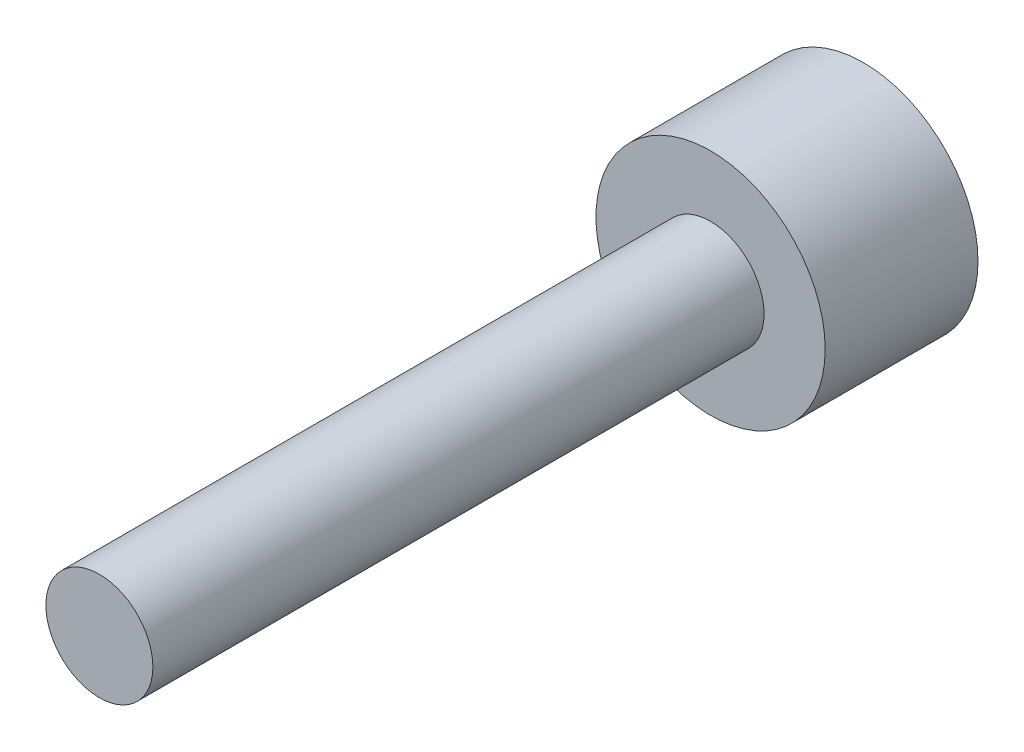
from build123d import *

# Parameters (mm, degrees)
SKETCH_1_R      = 0.7
EXTRUDE_1_DEPTH = 10
SKETCH_2_R      = 1.5
EXTRUDE_2_DEPTH = 2


with BuildPart() as part:
    # 草圖1 → 填料-伸長1 (new body)
    with BuildSketch(Plane.XY):
        Circle(SKETCH_1_R)
    extrude(amount=EXTRUDE_1_DEPTH)

    # 草圖2 → 填料-伸長2 (add)
    with BuildSketch(Plane.XY):
        Circle(SKETCH_2_R)
    extrude(amount=EXTRUDE_2_DEPTH)


solid = part.part
